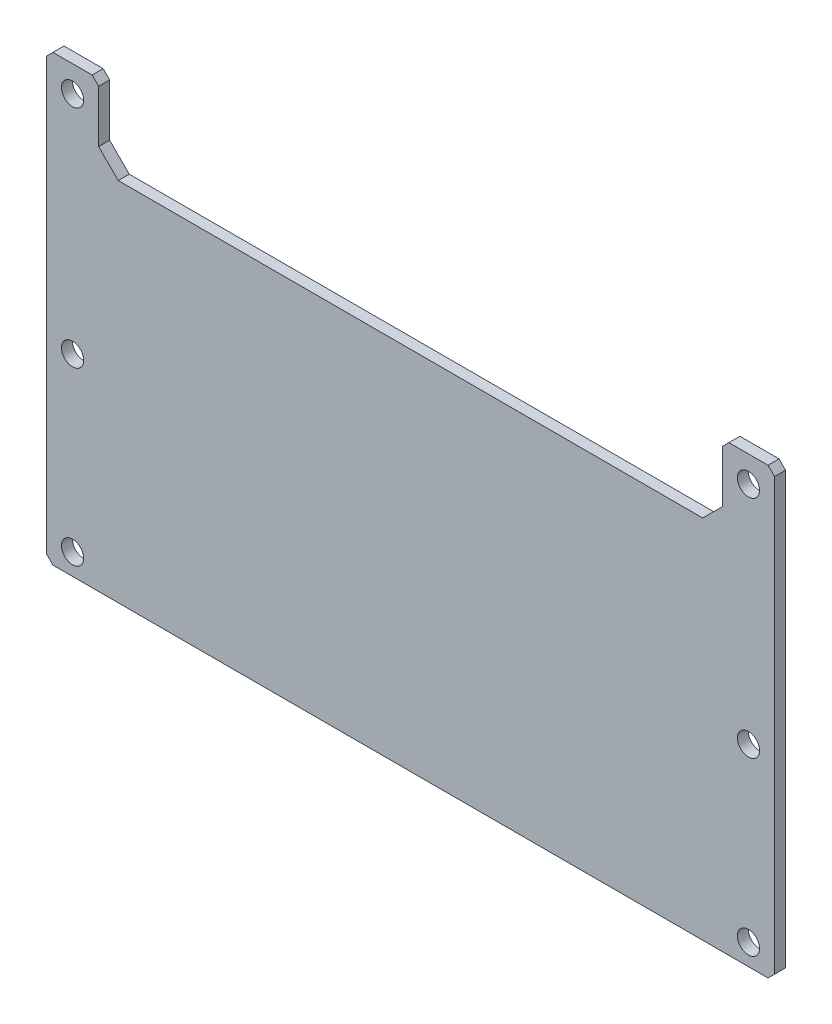
from build123d import *

# Parameters (mm, degrees)
SKETCH1_R           = 1.7
BOSS_EXTRUDE1_DEPTH = 1.68656


with BuildPart() as part:
    # Sketch1 → Boss-Extrude1 (new body)
    with BuildSketch(Plane.XY):
        Polygon((0, 1), (1, 0), (110.5, 0), (111.5, 1), (111.5, 67), (110.5, 68), (104.5, 68), (103.5, 67), (103.5, 59), (100.5, 56), (11, 56), (8, 59), (8, 67), (7, 68), (1, 68), (0, 67), align=None)
        with Locations((107.5, 29.5)):
            Circle(SKETCH1_R, mode=Mode.SUBTRACT)
        with Locations((107.5, 64)):
            Circle(SKETCH1_R, mode=Mode.SUBTRACT)
        with Locations((107.5, 3.25)):
            Circle(SKETCH1_R, mode=Mode.SUBTRACT)
        with Locations((4, 64)):
            Circle(SKETCH1_R, mode=Mode.SUBTRACT)
        with Locations((4, 29.5)):
            Circle(SKETCH1_R, mode=Mode.SUBTRACT)
        with Locations((4, 3.25)):
            Circle(SKETCH1_R, mode=Mode.SUBTRACT)
    extrude(amount=BOSS_EXTRUDE1_DEPTH)


solid = part.part
